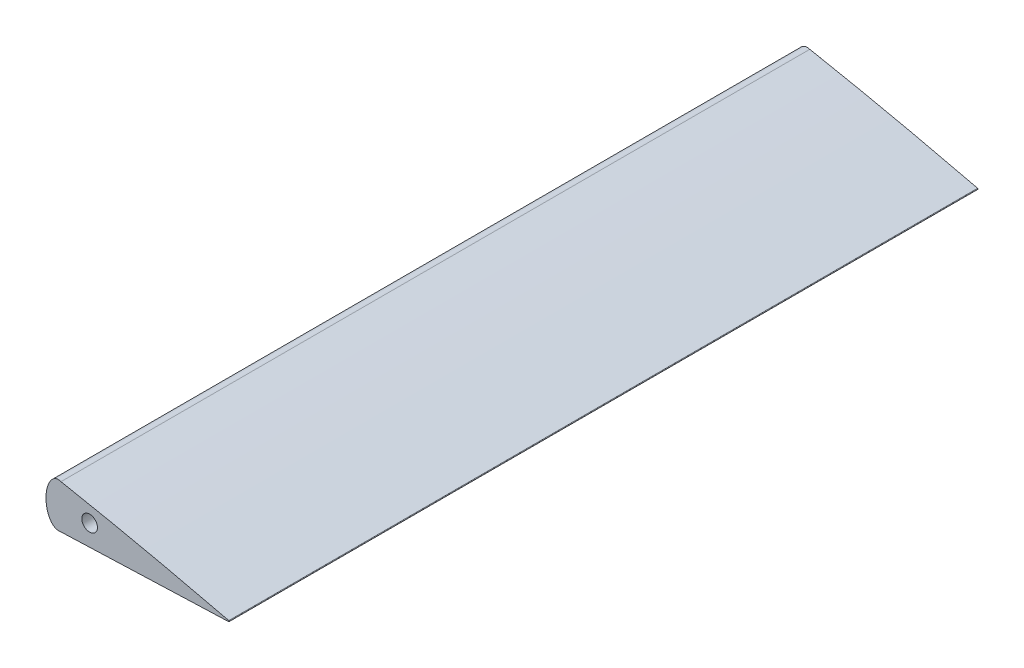
from build123d import *

# Parameters (mm, degrees)
BOSS_EXTRUDE1_DEPTH        = 1246.6
SKETCH3_W                  = 131.331771
SKETCH3_H                  = 32.627886
AILERON_CHORD_DEPTH        = 1246.6
AILERON_SPAN_DEPTH         = 10
AILERON_SPAN_DEPTH_BACK    = 10
SKETCH4_W                  = 171.070003
SKETCH4_H                  = 1110.639097
SKETCH5_R                  = 1.5
AILERON_SPAR_HOLE_DEPTH    = 219.292246
SKETCH6_RX                 = 4.241084
SKETCH6_RY                 = 2.380428
AILERON_LEADING_EDGE_DEPTH = 143.8


with BuildPart() as part:
    # Sketch2 → Boss-Extrude1 (new body)
    with BuildSketch(Plane.XY):
        with BuildLine():
            ThreePointArc((164, 0.098236), (164.077667, 0), (164, -0.098236))
            add(Edge.make_bspline(
                [(164, 0.098236), (163.453347, 0.227855), (162.360116, 0.487077), (160.720174, 0.874803), (159.080335, 1.261114), (156.894332, 1.771897), (154.161962, 2.401008), (150.881841, 3.137526), (147.601665, 3.856594), (144.321702, 4.559852), (141.041699, 5.246218), (137.761757, 5.915572), (134.481686, 6.566534), (131.201761, 7.199898), (127.921668, 7.813754), (124.641701, 8.409172), (121.361598, 8.98465), (118.081601, 9.541284), (114.801561, 10.078059), (111.521601, 10.595035), (108.241714, 11.090965), (104.961715, 11.562926), (101.681786, 12.010167), (98.401747, 12.429709), (95.121663, 12.8205), (91.841542, 13.181831), (88.561414, 13.51363), (85.281283, 13.815894), (82.001169, 14.088695), (78.721095, 14.331741), (75.441021, 14.543175), (72.160895, 14.719913), (68.880726, 14.859428), (65.600503, 14.959161), (62.320225, 15.016118), (59.03999, 15.033011), (55.759815, 15.012804), (52.479681, 14.959634), (49.199602, 14.875645), (45.919233, 14.766825), (42.638538, 14.618827), (39.357416, 14.416023), (36.075798, 14.141603), (32.793534, 13.779736), (29.511749, 13.311849), (26.230435, 12.736941), (22.948211, 12.059087), (19.663974, 11.271431), (16.378115, 10.351738), (13.092739, 9.27165), (10.358156, 8.239856), (8.178743, 7.269153), (6.527119, 6.423629), (4.860633, 5.419015), (3.322168, 4.246728), (2.16678, 3.134219), (1.284844, 2.240038), (0.724778, 1.586326), (0.356487, 1.023715), (0.176339, 0.655159), (0.061261, 0.337633), (-0.042912, -0.12114), (0.010077, -0.598533), (0.176199, -1.014078), (0.354673, -1.344525), (0.71711, -1.82624), (1.269773, -2.336775), (2.131754, -2.920204), (3.354944, -3.392789), (4.915318, -3.707167), (6.554156, -4.03305), (8.195339, -4.283516), (10.38227, -4.5154), (13.118625, -4.672653), (16.398858, -4.828476), (19.679494, -4.922127), (22.959844, -4.966534), (26.240095, -4.967885), (29.520218, -4.932841), (32.800258, -4.868949), (36.080251, -4.782672), (39.360206, -4.679002), (42.64013, -4.562992), (45.920051, -4.439945), (49.199963, -4.314096), (52.479955, -4.190749), (55.759981, -4.070022), (59.039983, -3.95008), (62.320004, -3.83127), (65.600009, -3.712064), (68.880009, -3.592327), (72.16001, -3.47216), (75.439998, -3.351295), (78.720004, -3.230701), (81.999996, -3.109715), (85.279997, -2.989046), (88.559997, -2.868485), (91.84, -2.748159), (95.12, -2.627768), (98.4, -2.5074), (101.68, -2.387008), (104.960004, -2.266687), (108.24, -2.146109), (111.519996, -2.025503), (114.800005, -1.905264), (118.079995, -1.784568), (121.360005, -1.664353), (124.639995, -1.54365), (127.920005, -1.423438), (131.199995, -1.302734), (134.480005, -1.182522), (137.759995, -1.061818), (141.040005, -0.941606), (144.319995, -0.820902), (147.600005, -0.70069), (150.879995, -0.579986), (154.160005, -0.459776), (156.89333, -0.359182), (159.08, -0.278973), (160.72, -0.218763), (162.360004, -0.158632), (163.453334, -0.118368), (164, -0.098236)],
                knots=[0, 0, 0, 0, 0.005028, 0.010055, 0.015081, 0.020105, 0.030145, 0.040174, 0.050191, 0.060198, 0.070194, 0.08018, 0.090156, 0.100121, 0.110076, 0.12002, 0.129954, 0.139879, 0.149793, 0.159699, 0.169594, 0.17948, 0.189355, 0.199219, 0.209073, 0.218917, 0.228751, 0.238577, 0.248396, 0.258207, 0.268012, 0.277811, 0.287604, 0.297393, 0.307179, 0.316964, 0.326749, 0.336535, 0.346322, 0.356113, 0.365908, 0.375711, 0.385531, 0.395376, 0.405259, 0.415192, 0.425184, 0.435248, 0.445412, 0.455711, 0.466191, 0.471552, 0.477055, 0.482787, 0.488946, 0.494316, 0.497126, 0.500187, 0.502001, 0.503128, 0.50385, 0.50502, 0.507318, 0.507987, 0.509024, 0.510668, 0.513358, 0.515716, 0.519949, 0.524973, 0.529954, 0.534903, 0.539824, 0.54963, 0.559425, 0.569214, 0.579, 0.588784, 0.59857, 0.608356, 0.618144, 0.627933, 0.637724, 0.647515, 0.657307, 0.667099, 0.67689, 0.686681, 0.696472, 0.706263, 0.716054, 0.725846, 0.735637, 0.745428, 0.755219, 0.765011, 0.774802, 0.784593, 0.794384, 0.804176, 0.813967, 0.823758, 0.833549, 0.84334, 0.853132, 0.862923, 0.872714, 0.882505, 0.892297, 0.902088, 0.911879, 0.92167, 0.931461, 0.941253, 0.951044, 0.960835, 0.970626, 0.980418, 0.985313, 0.990209, 0.995104, 1, 1, 1, 1], degree=3))
        make_face()
    extrude(amount=BOSS_EXTRUDE1_DEPTH)

    # Sketch3 → Aileron chord (cut)
    with BuildSketch(Plane.XY.offset(1246.6)):
        with Locations((65.611782, 9.808584)):
            Rectangle(SKETCH3_W, SKETCH3_H)
    extrude(amount=-AILERON_CHORD_DEPTH, mode=Mode.SUBTRACT)

    # Sketch4 → Aileron span (cut, two sides: drawn at the far end of the back side and taken through both)
    with BuildSketch(Plane(origin=(0, 0, 0), x_dir=(1, 0, 0), z_dir=(0, 1, 0)).offset(-AILERON_SPAN_DEPTH_BACK)):
        with Locations((146.361743, -699.119548)):
            Rectangle(SKETCH4_W, SKETCH4_H)
    extrude(amount=AILERON_SPAN_DEPTH + AILERON_SPAN_DEPTH_BACK, mode=Mode.SUBTRACT)

    # Sketch5 → Aileron spar hole (cut, through all)
    with BuildSketch(Plane(origin=(0, 0, 0), x_dir=(-1, 0, 0), z_dir=(0, 0, -1))):
        with Locations((-137.277667, 2.94112)):
            Circle(SKETCH5_R)
    extrude(amount=-AILERON_SPAR_HOLE_DEPTH, mode=Mode.SUBTRACT)

    # Sketch6 → Aileron leading edge (add)
    with BuildSketch(Plane(origin=(0, 0, 0), x_dir=(-1, 0, 0), z_dir=(0, 0, -1))):
        with Locations(Location((-131.277667, 2.94112), (0, 0, 90))):
            Ellipse(SKETCH6_RX, SKETCH6_RY)
    extrude(amount=-AILERON_LEADING_EDGE_DEPTH)


solid = part.part
